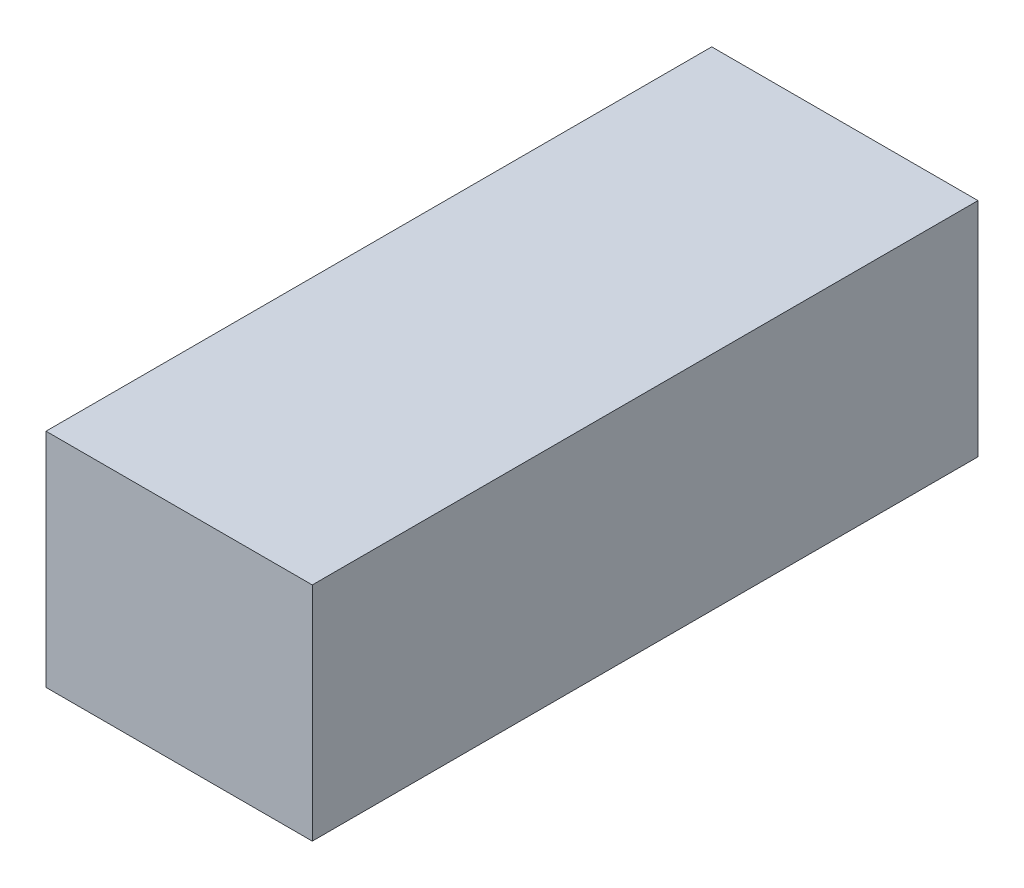
from build123d import *

# Parameters (mm, degrees)
SKETCH1_W           = 18
SKETCH1_H           = 45
BOSS_EXTRUDE1_DEPTH = 15


with BuildPart() as part:
    # Sketch1 → Boss-Extrude1 (new body)
    with BuildSketch(Plane(origin=(0, 0, 0), x_dir=(1, 0, 0), z_dir=(0, 1, 0))):
        with Locations((7.330645161, 0)):
            Rectangle(SKETCH1_W, SKETCH1_H)
    extrude(amount=BOSS_EXTRUDE1_DEPTH)


solid = part.part
